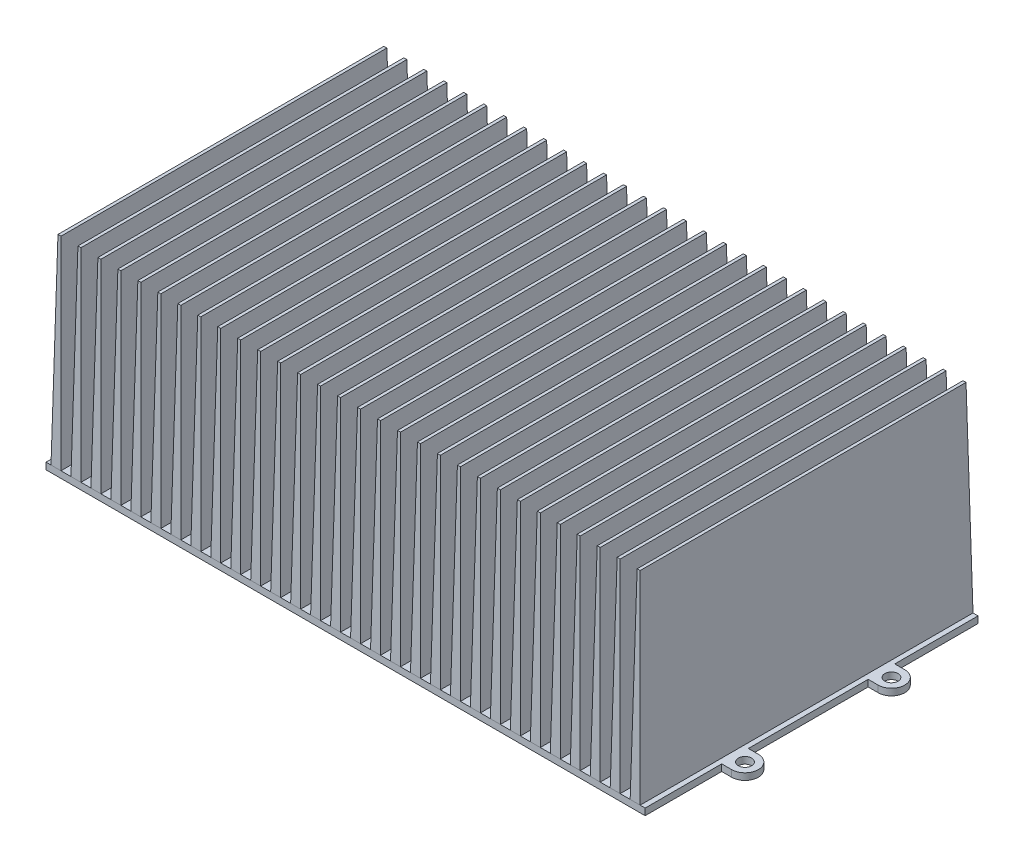
from build123d import *

# Parameters (mm, degrees)
SKETCH1_W               = 180
SKETCH1_H               = 100
BOSS_EXTRUDE1_DEPTH     = 2
SKETCH2_W               = 3
SKETCH2_H               = 100
BOSS_EXTRUDE2_DEPTH     = 60
BOSS_EXTRUDE2_TAPER     = 1
LPATTERN1_COUNT         = 30
LPATTERN1_PITCH         = 6
SKETCH3_R               = 2
BOSS_EXTRUDE3_DEPTH     = 2
LPATTERN2_COUNT         = 2
LPATTERN2_PITCH         = 44
MIRROR2_COPY_1_SKETCH_R = 2
MIRROR2_COPY_1_DEPTH    = 2


with BuildPart() as part:
    # Sketch1 → Boss-Extrude1 (new body)
    with BuildSketch(Plane(origin=(0, 0, 0), x_dir=(1, 0, 0), z_dir=(0, 1, 0))):
        Rectangle(SKETCH1_W, SKETCH1_H)
    extrude(amount=BOSS_EXTRUDE1_DEPTH)

    # Sketch2 → Boss-Extrude2 (add)
    with BuildSketch(Plane(origin=(0, 2, 0), x_dir=(1, 0, 0), z_dir=(0, 1, 0))):
        with Locations((87, 0)):
            Rectangle(SKETCH2_W, SKETCH2_H)
    boss_extrude2 = extrude(amount=BOSS_EXTRUDE2_DEPTH, taper=BOSS_EXTRUDE2_TAPER)

    # LPattern1: Boss-Extrude2 ×30
    with Locations(*[(-i * LPATTERN1_PITCH, 0, 0) for i in range(1, LPATTERN1_COUNT)]):
        add(boss_extrude2)

    # Sketch3 → Boss-Extrude3 (add)
    with BuildSketch(Plane(origin=(0, 2, 0), x_dir=(1, 0, 0), z_dir=(0, 1, 0))):
        with BuildLine():
            ThreePointArc((93, -27), (97, -23), (93, -19))
            Line((93, -19), (90, -19))
            Line((90, -19), (90, -27))
            Line((90, -27), (93, -27))
        make_face()
        with Locations((93, -23)):
            Circle(SKETCH3_R, mode=Mode.SUBTRACT)
    boss_extrude3 = extrude(amount=-BOSS_EXTRUDE3_DEPTH)

    # LPattern2: Boss-Extrude3 ×2
    with Locations(*[(0, 0, -i * LPATTERN2_PITCH) for i in range(1, LPATTERN2_COUNT)]):
        add(boss_extrude3)

    # Mirror2: Boss-Extrude3 across plane
    add(boss_extrude3.mirror(Plane(origin=(0, 0, 0), x_dir=(0, 0, 1), z_dir=(1, 0, 0))))

    # Mirror2 copy 1 sketch → Mirror2 copy 1 (add)
    with BuildSketch(Plane(origin=(0, 2, -44), x_dir=(-1, 0, 0), z_dir=(0, 1, 0))):
        with BuildLine():
            ThreePointArc((93, 27), (97, 23), (93, 19))
            Line((93, 19), (90, 19))
            Line((90, 19), (90, 27))
            Line((90, 27), (93, 27))
        make_face()
        with Locations((93, 23)):
            Circle(MIRROR2_COPY_1_SKETCH_R, mode=Mode.SUBTRACT)
    extrude(amount=-MIRROR2_COPY_1_DEPTH)


solid = part.part
